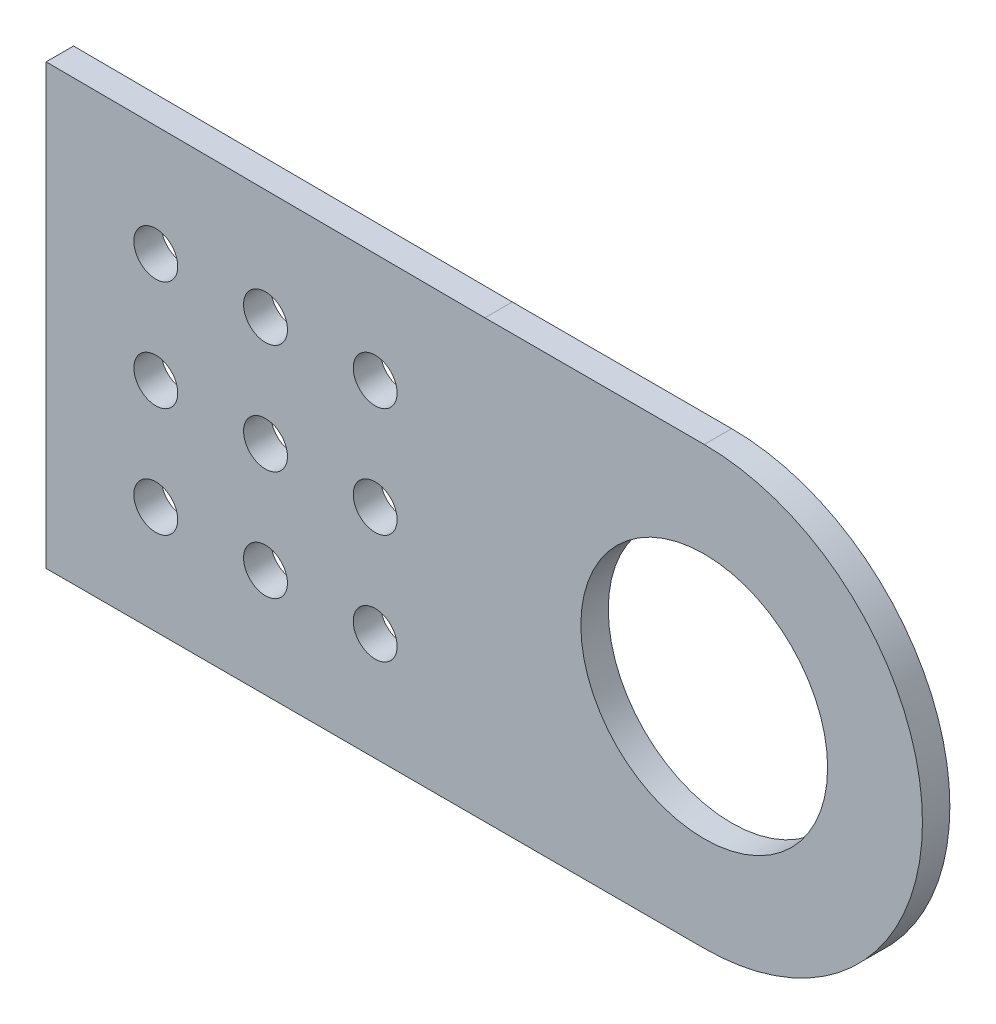
from build123d import *

# Parameters (mm, degrees)
SKETCH1_R           = 2.54
SKETCH1_R_2         = 14.2875
BOSS_EXTRUDE1_DEPTH = 3.175


with BuildPart() as part:
    # Sketch1 → Boss-Extrude1 (new body)
    with BuildSketch(Plane.XY):
        with BuildLine():
            Line((0, 0), (0, 50.8))
            Line((0, 50.8), (50.8, 50.534405745))
            Line((50.8, 50.534405745), (76.2, 50.534405745))
            ThreePointArc((76.2, 50.534405745), (101.467202873, 25.267202873), (76.2, 0))
            Line((76.2, 0), (0, 0))
        make_face()
        with Locations((12.7, 37.900630736)):
            Circle(SKETCH1_R, mode=Mode.SUBTRACT)
        with Locations((25.4, 37.900630736)):
            Circle(SKETCH1_R, mode=Mode.SUBTRACT)
        with Locations((38.1, 37.900630736)):
            Circle(SKETCH1_R, mode=Mode.SUBTRACT)
        with Locations((25.4, 25.200630736)):
            Circle(SKETCH1_R, mode=Mode.SUBTRACT)
        with Locations((38.1, 25.200630736)):
            Circle(SKETCH1_R, mode=Mode.SUBTRACT)
        with Locations((25.4, 12.500630736)):
            Circle(SKETCH1_R, mode=Mode.SUBTRACT)
        with Locations((38.1, 12.500630736)):
            Circle(SKETCH1_R, mode=Mode.SUBTRACT)
        with Locations((12.7, 25.200630736)):
            Circle(SKETCH1_R, mode=Mode.SUBTRACT)
        with Locations((12.7, 12.500630736)):
            Circle(SKETCH1_R, mode=Mode.SUBTRACT)
        with Locations((76.2, 25.267202873)):
            Circle(SKETCH1_R_2, mode=Mode.SUBTRACT)
    extrude(amount=BOSS_EXTRUDE1_DEPTH)


solid = part.part
